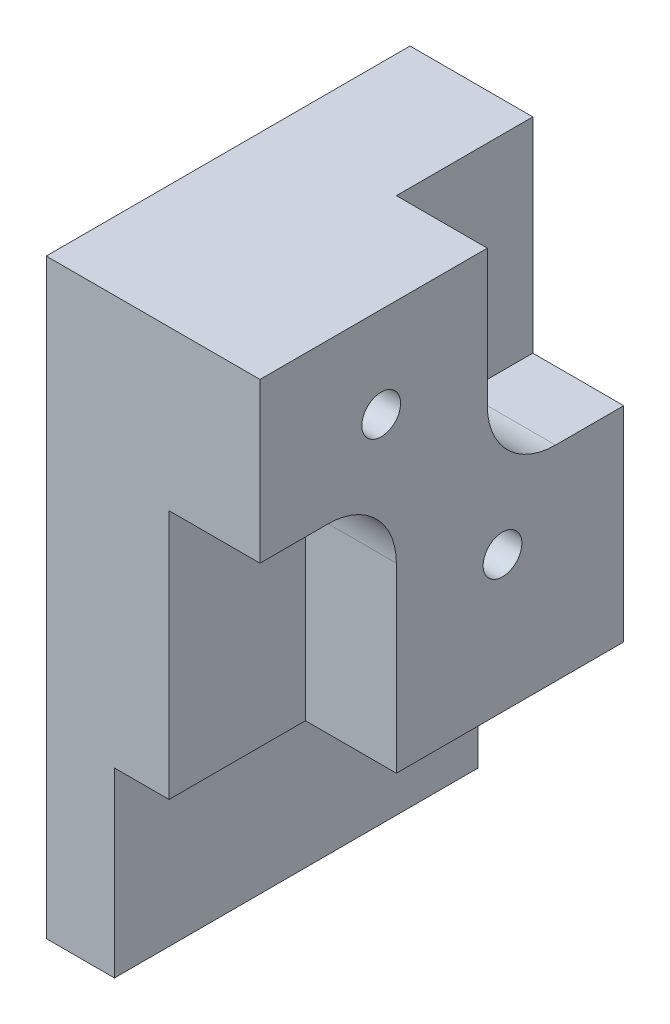
from build123d import *

# Parameters (mm, degrees)
BOSS_EXTRUDE1_DEPTH       = 25.4
TAP_DRILL_FOR_6_32_TAP1_D = 2.7051
SKETCH5_R                 = 4.7625
CUT_EXTRUDE1_DEPTH        = 6.35


with BuildPart() as part:
    # Sketch1 → Boss-Extrude1 (new body)
    with BuildSketch(Plane.XY):
        Polygon((-30.169054899, -23.479397625), (-25.406554899, -23.479397625), (-25.406554899, -10.779397625), (-15.246554899, -10.779397625), (-15.246554899, -7.604397625), (-15.246554899, 17.795602375), (-30.169054899, 17.795602375), (-30.169054899, -7.604397625), align=None)
    extrude(amount=BOSS_EXTRUDE1_DEPTH)

    # Tap Drill for #6-32 Tap1 (through all)
    with Locations(Plane(origin=(-15.246554899, 11.445602375, 16.933333333), x_dir=(0, 1, 0), z_dir=(1, 0, 0))):
        with Locations((0, 0), (-12.7, -8.466666666)):
            Hole(TAP_DRILL_FOR_6_32_TAP1_D / 2)

    # Sketch5 → Cut-Extrude1 (cut)
    with BuildSketch(Plane(origin=(-15.246554899, 0, 0), x_dir=(0, 0, -1), z_dir=(1, 0, 0))):
        with Locations((-20.6375, 1.920602375)):
            Circle(SKETCH5_R)
        with BuildLine():
            ThreePointArc((-25.4, 1.920602382), (-24.005096043, 5.288198423), (-20.6375, 6.683102375))
            Line((-20.6375, 6.683102375), (-25.4, 6.683102375))
            Line((-25.4, 6.683102375), (-25.4, 1.920602382))
        make_face()
        with BuildLine():
            Line((-15.875, -10.779397625), (-15.875, 1.920602375))
            ThreePointArc((-15.875, 1.920602375), (-20.637500004, -2.841897625), (-25.4, 1.920602382))
            Line((-25.4, 1.920602382), (-25.4, -10.779397625))
            Line((-25.4, -10.779397625), (-15.875, -10.779397625))
        make_face()
        with BuildLine():
            Line((0, 17.795602375), (-9.525, 17.795602375))
            Line((-9.525, 17.795602375), (-9.525, 8.270602375))
            ThreePointArc((-9.525, 8.270602375), (-4.7625, 13.033102375), (0, 8.270602375))
            Line((0, 8.270602375), (0, 17.795602375))
        make_face()
        with Locations((-4.7625, 8.270602375)):
            Circle(SKETCH5_R)
        with BuildLine():
            Line((-4.7625, 3.508102375), (0, 3.508102375))
            Line((0, 3.508102375), (0, 8.270602375))
            ThreePointArc((0, 8.270602375), (-1.394903955, 4.90300633), (-4.7625, 3.508102375))
        make_face()
    extrude(amount=-CUT_EXTRUDE1_DEPTH, mode=Mode.SUBTRACT)


solid = part.part
